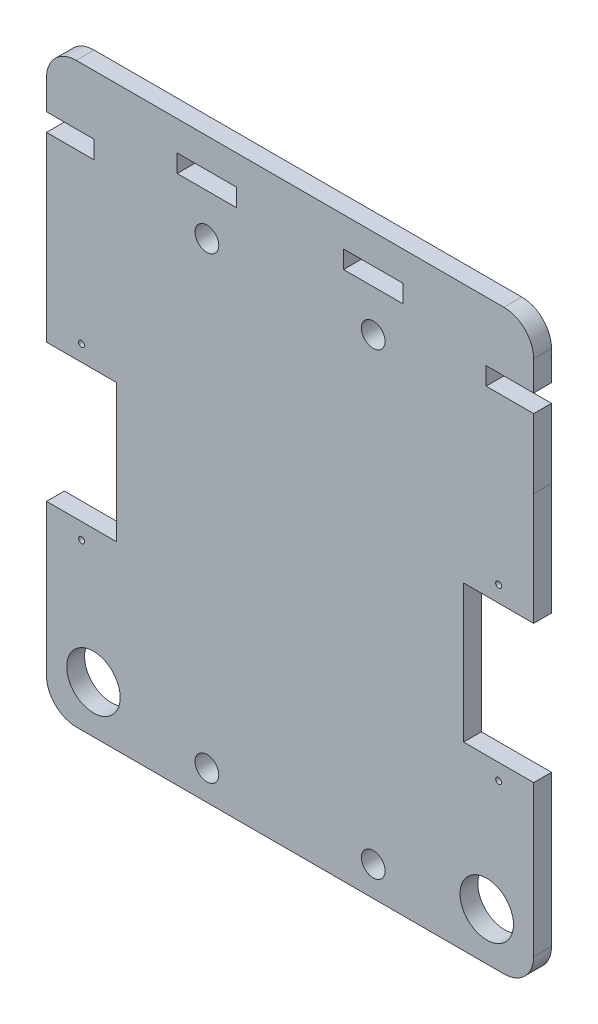
from build123d import *

# Parameters (mm, degrees)
MODEL_R                 = 2
MODEL_R_2               = 4.5
MODEL_R_3               = 0.5
MODEL_W                 = 10
MODEL_H                 = 3
SALIENTE_EXTRUIR1_DEPTH = 3


with BuildPart() as part:
    # Model → Saliente-Extruir1 (new body)
    with BuildSketch(Plane.XY):
        with BuildLine():
            Line((0.468281908, 11.04000444), (0.468281908, -14.359995173))
            ThreePointArc((0.468281908, -14.359995173), (1.932748002, -17.895529078), (5.468281908, -19.359995173))
            Line((5.468281908, -19.359995173), (77.465215563, -19.35999556))
            ThreePointArc((77.465215563, -19.35999556), (81.000749469, -17.895529466), (82.465215563, -14.35999556))
            Line((82.465215563, -14.35999556), (82.465215563, -9.05498571))
            Line((82.465215563, -9.05498571), (82.465215563, 11.04000444))
            Line((82.465215563, 11.04000444), (70.665215563, 11.04000444))
            Line((70.665215563, 11.04000444), (70.665215563, 34.24000444))
            Line((70.665215563, 34.24000444), (82.465215563, 34.24000444))
            Line((82.465215563, 34.24000444), (82.465215563, 53.145358109))
            Line((82.465215563, 53.145358109), (82.462149219, 64.823793593))
            Line((82.462149219, 64.823793593), (74.462149219, 64.823793593))
            Line((74.462149219, 64.823793593), (74.462149219, 67.823793593))
            Line((74.462149219, 67.823793593), (82.462149219, 67.823793593))
            Line((82.462149219, 67.823793593), (82.465215563, 72.823793593))
            ThreePointArc((82.465215563, 72.823793593), (81.000749469, 76.359327499), (77.465215563, 77.823793593))
            Line((77.465215563, 77.823793593), (67.948183059, 77.823793593))
            Line((67.948183059, 77.823793593), (45.205743308, 77.823793593))
            Line((45.205743308, 77.823793593), (23.093632519, 77.823793593))
            Line((23.093632519, 77.823793593), (11.942122032, 77.823793593))
            Line((11.942122032, 77.823793593), (5.468281908, 77.823793593))
            ThreePointArc((5.468281908, 77.823793593), (1.932748002, 76.359327499), (0.468281908, 72.823793593))
            Line((0.468281908, 72.823793593), (0.468281908, 67.823793593))
            Line((0.468281908, 67.823793593), (8.468281908, 67.823793593))
            Line((8.468281908, 67.823793593), (8.468281908, 64.823793593))
            Line((8.468281908, 64.823793593), (0.468281908, 64.823793593))
            Line((0.468281908, 64.823793593), (0.468281908, 34.24000444))
            Line((0.468281908, 34.24000444), (12.268281908, 34.24000444))
            Line((12.268281908, 34.24000444), (12.268281908, 11.04000444))
            Line((12.268281908, 11.04000444), (0.468281908, 11.04000444))
        make_face()
        with Locations((55.465215563, 62.823793593)):
            Circle(MODEL_R, mode=Mode.SUBTRACT)
        with Locations((27.465215563, 62.823793593)):
            Circle(MODEL_R, mode=Mode.SUBTRACT)
        with Locations((55.465215563, -14.35999556)):
            Circle(MODEL_R, mode=Mode.SUBTRACT)
        with Locations((27.465215563, -14.35999556)):
            Circle(MODEL_R, mode=Mode.SUBTRACT)
        with Locations((74.565215563, -11.35999556)):
            Circle(MODEL_R_2, mode=Mode.SUBTRACT)
        with Locations((8.365215563, -11.35999556)):
            Circle(MODEL_R_2, mode=Mode.SUBTRACT)
        with Locations((6.365215563, 8.34000444)):
            Circle(MODEL_R_3, mode=Mode.SUBTRACT)
        with Locations((6.365215563, 36.94000444)):
            Circle(MODEL_R_3, mode=Mode.SUBTRACT)
        with Locations((76.565215563, 8.34000444)):
            Circle(MODEL_R_3, mode=Mode.SUBTRACT)
        with Locations((76.565215563, 36.94000444)):
            Circle(MODEL_R_3, mode=Mode.SUBTRACT)
        with Locations((55.465215563, 71.323793593)):
            Rectangle(MODEL_W, MODEL_H, mode=Mode.SUBTRACT)
        with Locations((27.465215563, 71.323793593)):
            Rectangle(MODEL_W, MODEL_H, mode=Mode.SUBTRACT)
    extrude(amount=SALIENTE_EXTRUIR1_DEPTH)


solid = part.part
